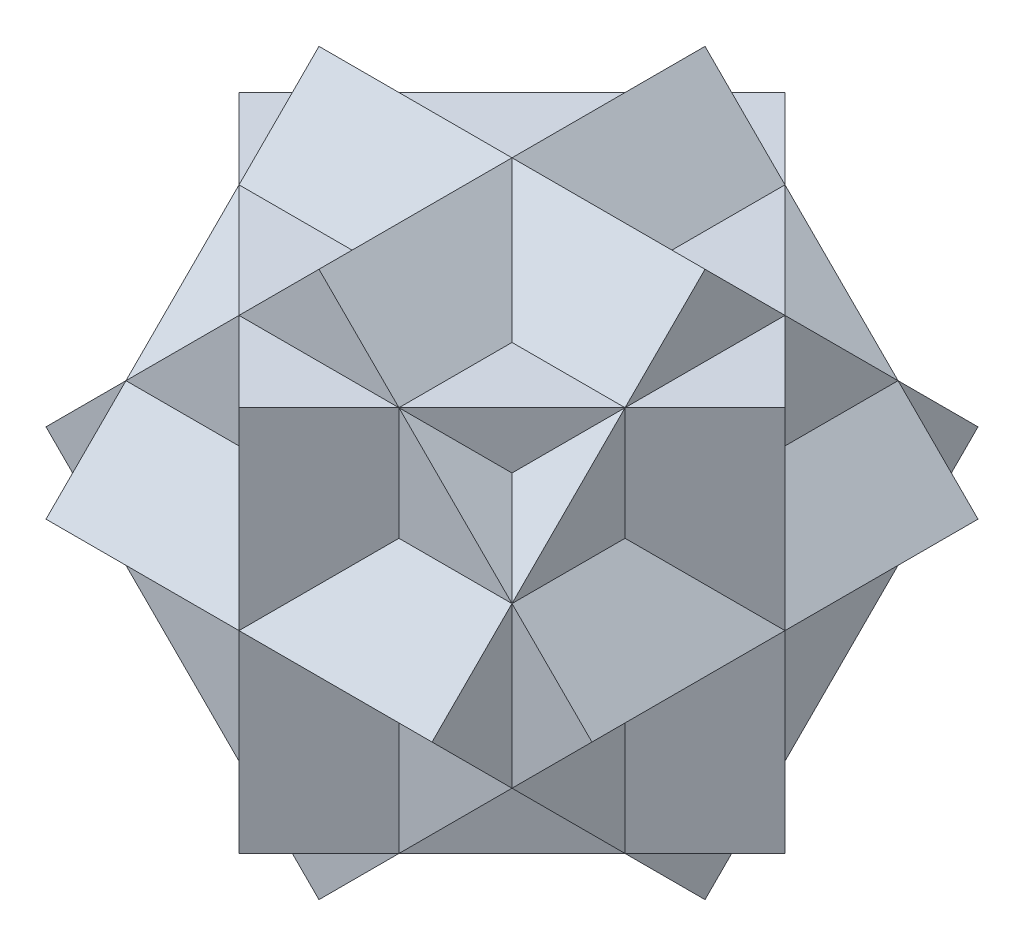
from build123d import *

# Parameters (mm, degrees)
BOSS_EXTRUDE1_DEPTH = 113.704878
BOSS_EXTRUDE2_DEPTH = 113.704878
BOSS_EXTRUDE3_DEPTH = 113.704878


with BuildPart() as part:
    # Sketch3 → Boss-Extrude1 (new, symmetric)
    with BuildSketch(Plane.XY):
        Polygon((-160.802980576, 0), (0, 160.802980576), (160.802980576, 0), (0, -160.802980576), align=None)
    extrude(amount=BOSS_EXTRUDE1_DEPTH, both=True)

    # Sketch4 → Boss-Extrude2 (add, symmetric)
    with BuildSketch(Plane(origin=(0, 0, 0), x_dir=(1, 0, 0), z_dir=(0, 1, 0))):
        Polygon((-160.802980576, 0), (0, 160.802980576), (160.802980576, 0), (0, -160.802980576), align=None)
    extrude(amount=BOSS_EXTRUDE2_DEPTH, both=True)

    # Sketch5 → Boss-Extrude3 (add, symmetric)
    with BuildSketch(Plane(origin=(0, 0, 0), x_dir=(0, 0, -1), z_dir=(1, 0, 0))):
        Polygon((-160.802980576, 0), (0, 160.802980576), (160.802980576, 0), (0, -160.802980576), align=None)
    extrude(amount=BOSS_EXTRUDE3_DEPTH, both=True)


solid = part.part
